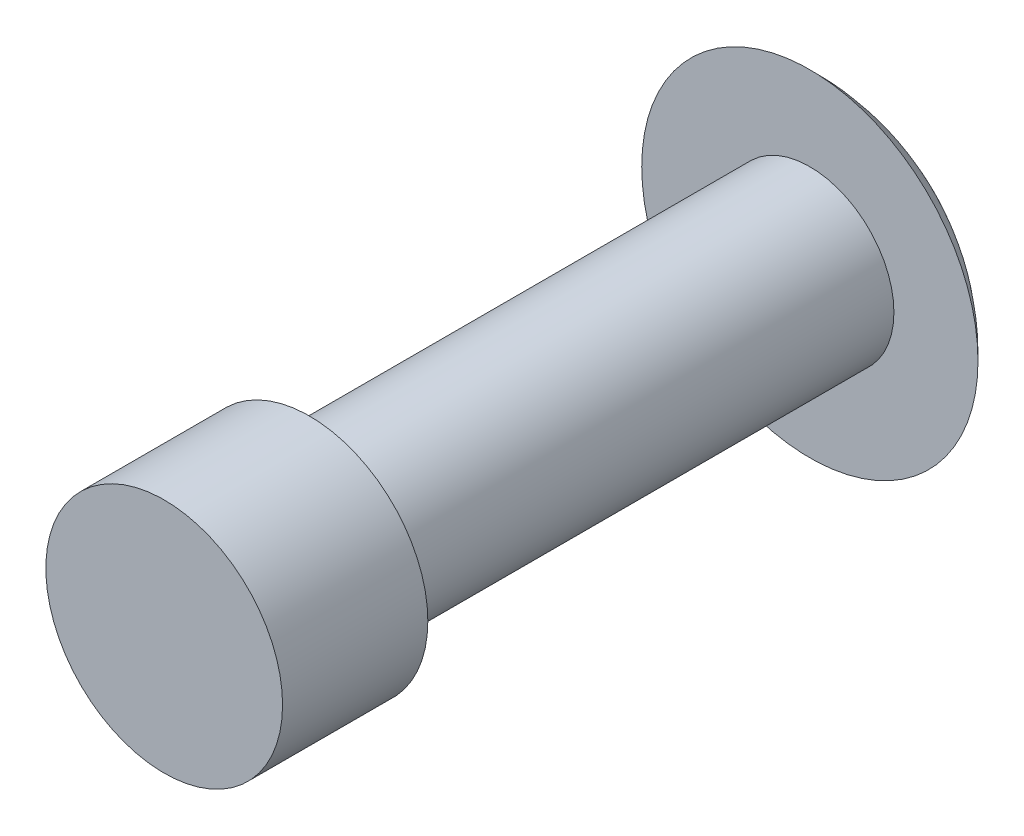
from build123d import *

# Parameters (mm, degrees)
SKETCH1_R          = 1.984375
BASE_EXTRUDE_DEPTH = 15.24
SKETCH3_R          = 2.794
EXTRUDE1_DEPTH     = 3.429


with BuildPart() as part:
    # Sketch1 → Base-Extrude (new body)
    with BuildSketch(Plane.XY):
        Circle(SKETCH1_R)
    extrude(amount=BASE_EXTRUDE_DEPTH)

    # Sketch2 → Boss-Revolve1 (revolve)
    with BuildSketch(Plane(origin=(0, 0, 0), x_dir=(1, 0, 0), z_dir=(0, 1, 0))):
        with BuildLine():
            Line((0, 1.7018), (0, 0))
            Line((0, 0), (3.96875, 0))
            ThreePointArc((3.96875, 0), (2.15911439, 1.258407907), (0, 1.7018))
        make_face()
    revolve(axis=Axis((0, 0, 0), (0, 0, -1)))

    # Sketch3 → Extrude1 (add)
    with BuildSketch(Plane.XY.offset(15.24)):
        Circle(SKETCH3_R)
    extrude(amount=-EXTRUDE1_DEPTH)


solid = part.part
